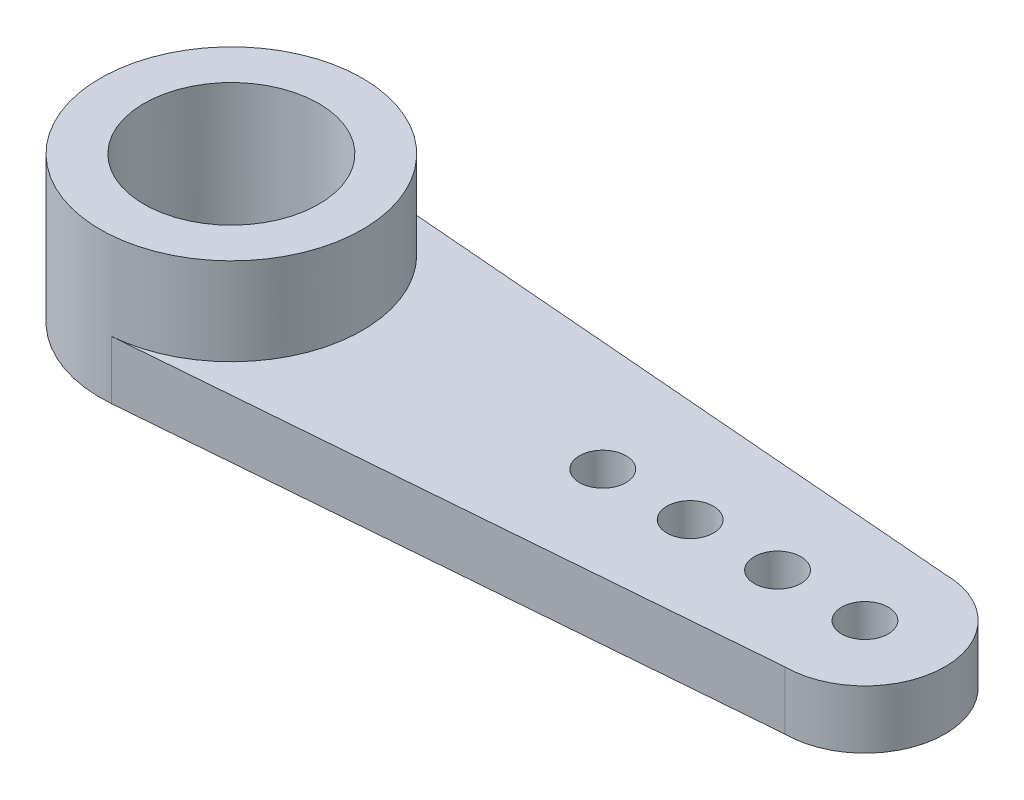
from build123d import *

# Parameters (mm, degrees)
SKETCH_1_R      = 3
SKETCH_1_R_2    = 0.8
EXTRUDE_1_DEPTH = 2
SKETCH_2_R      = 4.5
SKETCH_2_R_2    = 3
EXTRUDE_2_DEPTH = 3


with BuildPart() as part:
    # 草圖1 → 伸長1 (new body)
    with BuildSketch(Plane(origin=(0, 0, 0), x_dir=(1, 0, 0), z_dir=(0, 1, 0))):
        with BuildLine():
            Line((0.363932704, 4.485259523), (21.75, 2.75))
            ThreePointArc((21.75, 2.75), (24.5, 0), (21.75, -2.75))
            Line((21.75, -2.75), (0.363932704, -4.485259523))
            ThreePointArc((0.363932704, -4.485259523), (-4.5, 0), (0.363932704, 4.485259523))
        make_face()
        Circle(SKETCH_1_R, mode=Mode.SUBTRACT)
        with Locations((12.75, 0)):
            Circle(SKETCH_1_R_2, mode=Mode.SUBTRACT)
        with Locations((15.75, 0)):
            Circle(SKETCH_1_R_2, mode=Mode.SUBTRACT)
        with Locations((18.75, 0)):
            Circle(SKETCH_1_R_2, mode=Mode.SUBTRACT)
        with Locations((21.75, 0)):
            Circle(SKETCH_1_R_2, mode=Mode.SUBTRACT)
    extrude(amount=EXTRUDE_1_DEPTH)

    # 草圖2 → 伸長2 (add)
    with BuildSketch(Plane.XZ.offset(-2)):
        Circle(SKETCH_2_R)
        Circle(SKETCH_2_R_2, mode=Mode.SUBTRACT)
    extrude(amount=-EXTRUDE_2_DEPTH)


solid = part.part
